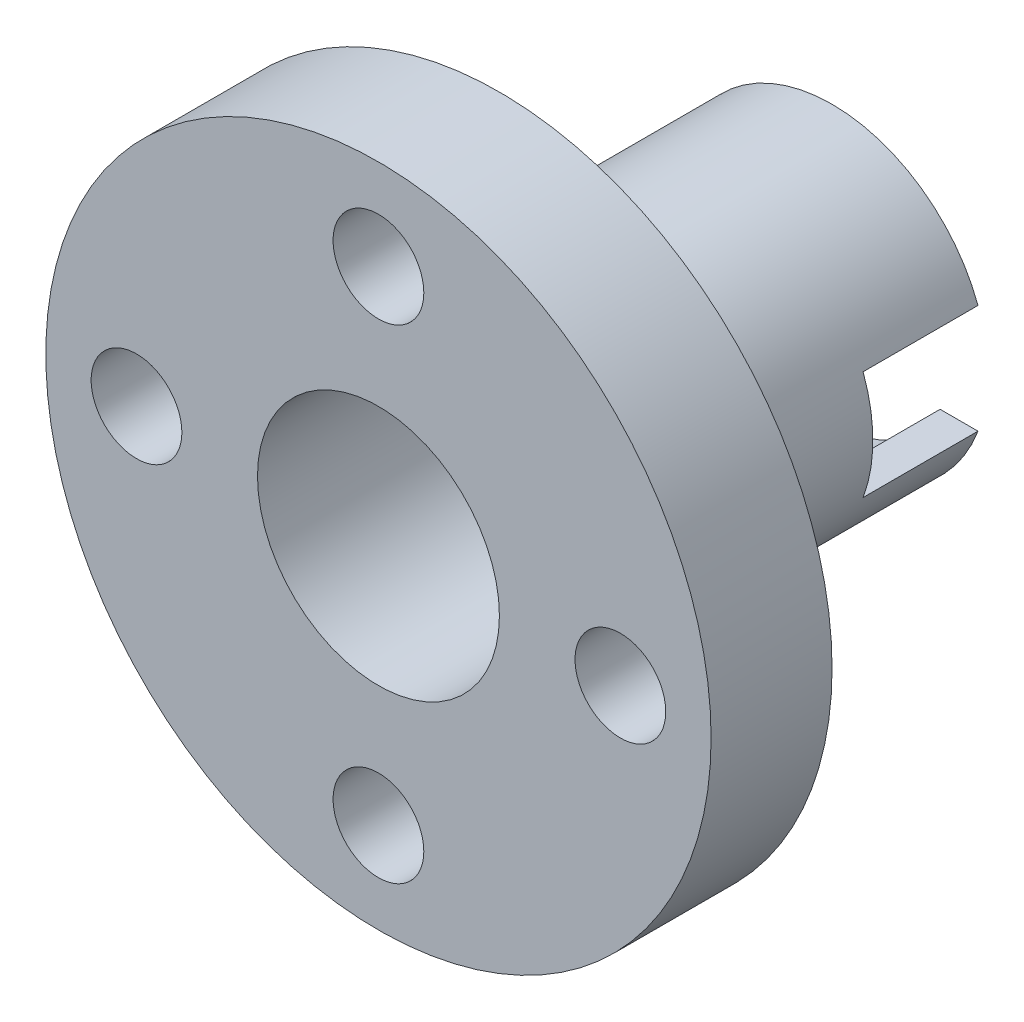
from build123d import *

# Parameters (mm, degrees)
SKETCH_1_R               = 11
SKETCH_1_R_2             = 1.5
EXTRUDE_1_DEPTH          = 4
SKETCH_2_R               = 5.15
EXTRUDE_2_DEPTH          = 11
SKETCH_3_R               = 4
CUT_EXTRUDE_1_DEPTH      = 1
CUT_EXTRUDE_1_DEPTH_BACK = 16
SKETCH_6_W               = 3.8
SKETCH_6_H               = 3.6
CUT_EXTRUDE_2_DEPTH      = 12
CUT_EXTRUDE_2_DEPTH_BACK = 12


with BuildPart() as part:
    # 草图1 → 凸台-拉伸1 (new body)
    with BuildSketch(Plane.XY):
        Circle(SKETCH_1_R)
        with Locations((-8, 0)):
            Circle(SKETCH_1_R_2, mode=Mode.SUBTRACT)
        with Locations((0, 8)):
            Circle(SKETCH_1_R_2, mode=Mode.SUBTRACT)
        with Locations((8, 0)):
            Circle(SKETCH_1_R_2, mode=Mode.SUBTRACT)
        with Locations((0, -8)):
            Circle(SKETCH_1_R_2, mode=Mode.SUBTRACT)
    extrude(amount=EXTRUDE_1_DEPTH)

    # 草图2 → 凸台-拉伸2 (add)
    with BuildSketch(Plane(origin=(0, 0, 0), x_dir=(-1, 0, 0), z_dir=(0, 0, -1))):
        Circle(SKETCH_2_R)
    extrude(amount=EXTRUDE_2_DEPTH)

    # 草图3 → 切除-拉伸1 (cut, two sides)
    with BuildSketch(Plane(origin=(0, 0, -11), x_dir=(-1, 0, 0), z_dir=(0, 0, -1))) as cut_extrude_1_sk:
        Circle(SKETCH_3_R)
    extrude(amount=CUT_EXTRUDE_1_DEPTH, mode=Mode.SUBTRACT)
    extrude(cut_extrude_1_sk.sketch, amount=-CUT_EXTRUDE_1_DEPTH_BACK, mode=Mode.SUBTRACT)

    # 草图6 → 切除-拉伸2 (cut, two sides)
    with BuildSketch(Plane.ZY) as cut_extrude_2_sk:
        with Locations((-9.1, 0)):
            Rectangle(SKETCH_6_W, SKETCH_6_H)
    extrude(amount=CUT_EXTRUDE_2_DEPTH, mode=Mode.SUBTRACT)
    extrude(cut_extrude_2_sk.sketch, amount=-CUT_EXTRUDE_2_DEPTH_BACK, mode=Mode.SUBTRACT)


solid = part.part
